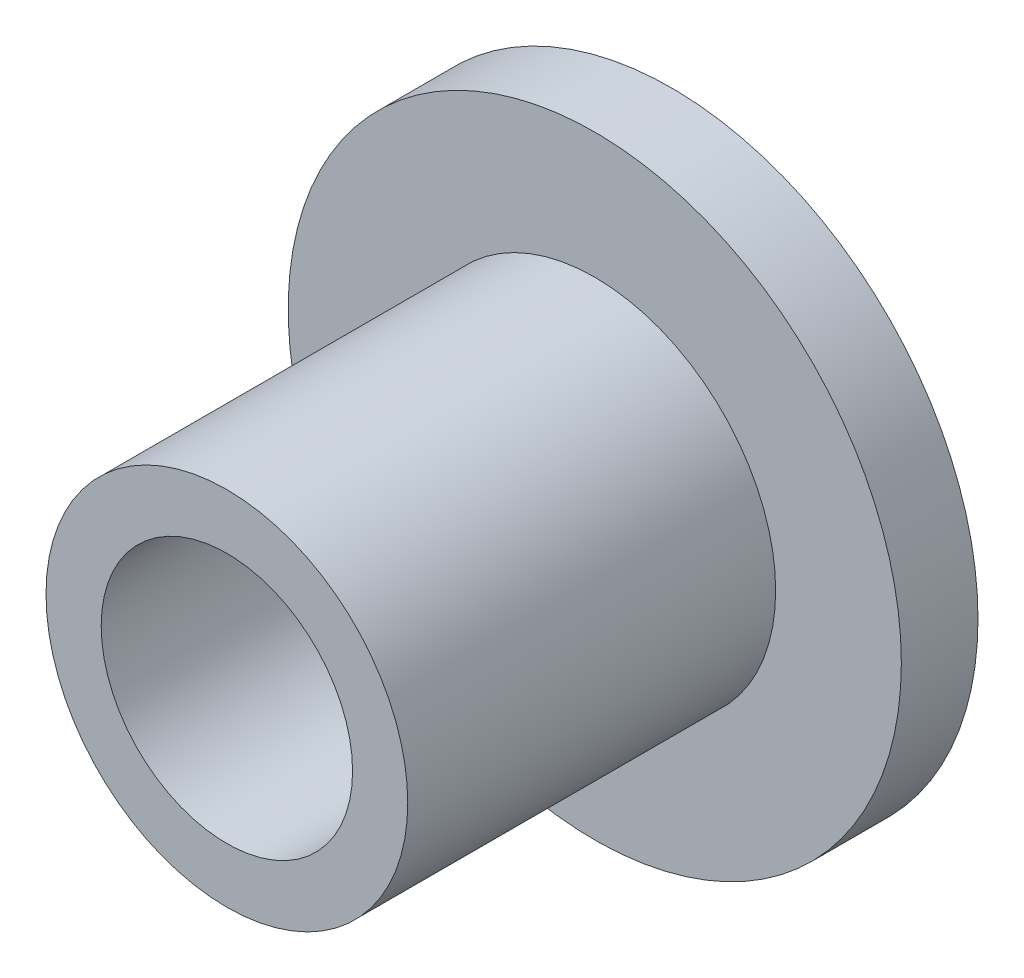
from build123d import *

# Parameters (mm, degrees)
SKETCH1_R           = 5
BOSS_EXTRUDE1_DEPTH = 1.25
SKETCH2_R           = 2.95
SKETCH2_R_2         = 2.05
BOSS_EXTRUDE2_DEPTH = 6
SKETCH4_R           = 2.05
CUT_EXTRUDE3_DEPTH  = 2.25
SKETCH5_R           = 3.05
CUT_EXTRUDE4_DEPTH  = 0.6


with BuildPart() as part:
    # Sketch1 → Boss-Extrude1 (new body)
    with BuildSketch(Plane.XY):
        Circle(SKETCH1_R)
    extrude(amount=BOSS_EXTRUDE1_DEPTH)

    # Sketch2 → Boss-Extrude2 (add)
    with BuildSketch(Plane.XY.offset(1.25)):
        Circle(SKETCH2_R)
        Circle(SKETCH2_R_2, mode=Mode.SUBTRACT)
    extrude(amount=BOSS_EXTRUDE2_DEPTH)

    # Sketch4 → Cut-Extrude3 (cut, through all)
    with BuildSketch(Plane.XY.offset(1.25)):
        Circle(SKETCH4_R)
    extrude(amount=-CUT_EXTRUDE3_DEPTH, mode=Mode.SUBTRACT)

    # Sketch5 → Cut-Extrude4 (cut)
    with BuildSketch(Plane(origin=(0, 0, 0), x_dir=(-1, 0, 0), z_dir=(0, 0, -1))):
        Circle(SKETCH5_R)
    extrude(amount=-CUT_EXTRUDE4_DEPTH, mode=Mode.SUBTRACT)


solid = part.part
